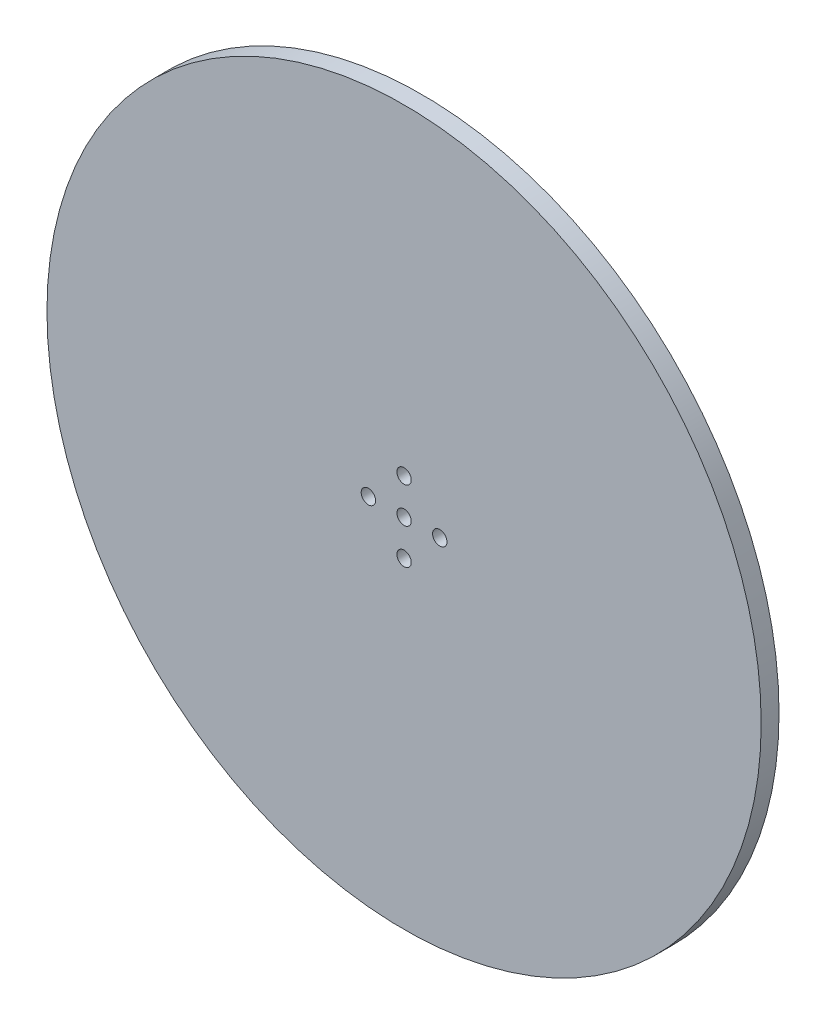
from build123d import *

# Parameters (mm, degrees)
SKETCH1_R           = 127
BOSS_EXTRUDE1_DEPTH = 6.35
SKETCH2_R           = 2.54
CUT_EXTRUDE1_DEPTH  = 7.35
CIRPATTERN1_COUNT   = 4


with BuildPart() as part:
    # Sketch1 → Boss-Extrude1 (new body)
    with BuildSketch(Plane.XY):
        Circle(SKETCH1_R)
    extrude(amount=BOSS_EXTRUDE1_DEPTH)

    # Sketch2 → Cut-Extrude1 (cut, through all)
    with BuildSketch(Plane.XY.offset(6.35)):
        Circle(SKETCH2_R)
    extrude(amount=-CUT_EXTRUDE1_DEPTH, mode=Mode.SUBTRACT)

    # Sketch5 → #10 Clearance Hole1 (revolve, cut)
    with BuildSketch(Plane(origin=(0, 12.7, 6.35), x_dir=(0, -1, 0), z_dir=(1, 0, 0))):
        Polygon((0, 0), (0, 11.058816902), (2.5527, 9.525), (2.5527, 0), align=None)
    f_10_clearance_hole1 = revolve(axis=Axis((0, 12.7, 12.7), (0, 0, -1)), mode=Mode.SUBTRACT)

    # CirPattern1: #10 Clearance Hole1 ×4 about axis
    cirpattern1_axis = Axis((0, 0, 0), (0, 0, 1))
    for i in range(1, CIRPATTERN1_COUNT):
        add(f_10_clearance_hole1.rotate(cirpattern1_axis, i * 360 / CIRPATTERN1_COUNT), mode=Mode.SUBTRACT)


solid = part.part
